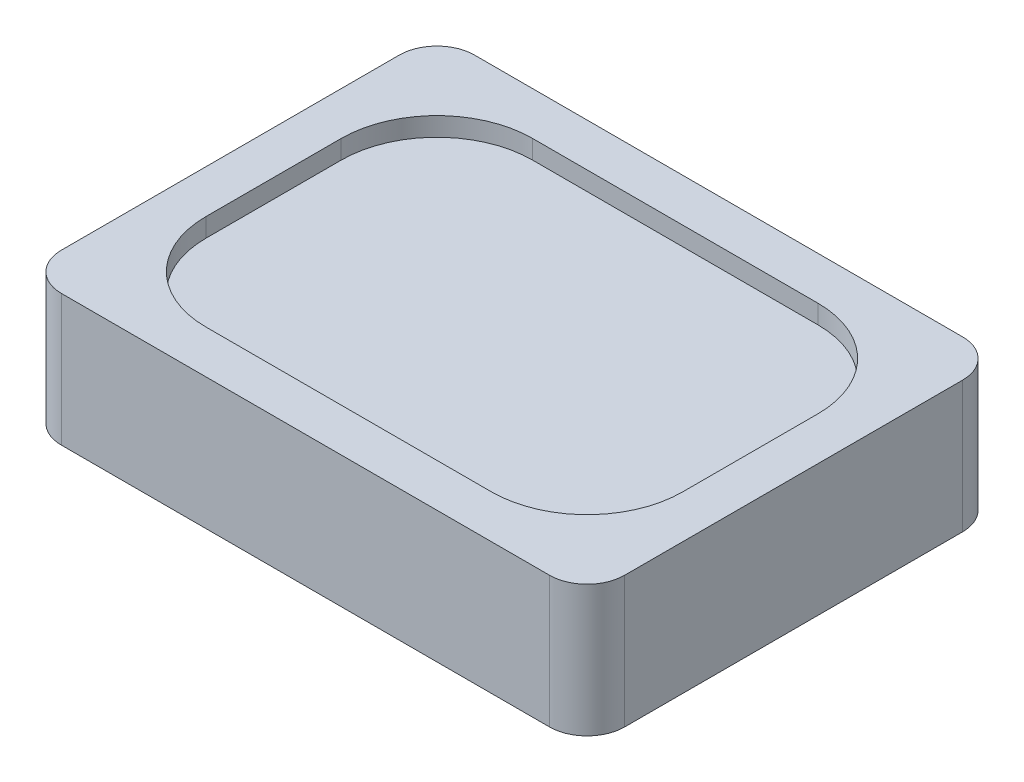
from build123d import *

# Parameters (mm, degrees)
SKETCH1_W           = 15
SKETCH1_H           = 11
BOSS_EXTRUDE1_DEPTH = 3.5
FILLET1_R           = 1
SKETCH2_W           = 12.7
SKETCH2_H           = 8.7
CUT_EXTRUDE1_DEPTH  = 0.5
FILLET2_R           = 2.55


with BuildPart() as part:
    # Sketch1 → Boss-Extrude1 (new body)
    with BuildSketch(Plane(origin=(0, 0, 0), x_dir=(1, 0, 0), z_dir=(0, 1, 0))):
        Rectangle(SKETCH1_W, SKETCH1_H)
    extrude(amount=BOSS_EXTRUDE1_DEPTH)

    # Fillet1
    fillet1_edges = [part.edges().sort_by_distance(p)[0] for p in [
        (7.5, 1.75, 5.5),
        (-7.5, 1.75, 5.5),
        (-7.5, 1.75, -5.5),
        (7.5, 1.75, -5.5),
    ]]
    fillet(fillet1_edges, radius=FILLET1_R)

    # Sketch2 → Cut-Extrude1 (cut)
    with BuildSketch(Plane(origin=(0, 3.5, 0), x_dir=(1, 0, 0), z_dir=(0, 1, 0))):
        Rectangle(SKETCH2_W, SKETCH2_H)
    extrude(amount=-CUT_EXTRUDE1_DEPTH, mode=Mode.SUBTRACT)

    # Fillet2
    fillet2_edges = [part.edges().sort_by_distance(p)[0] for p in [
        (6.35, 3.25, -4.35),
        (6.35, 3.25, 4.35),
        (-6.35, 3.25, 4.35),
        (-6.35, 3.25, -4.35),
    ]]
    fillet(fillet2_edges, radius=FILLET2_R)


solid = part.part
